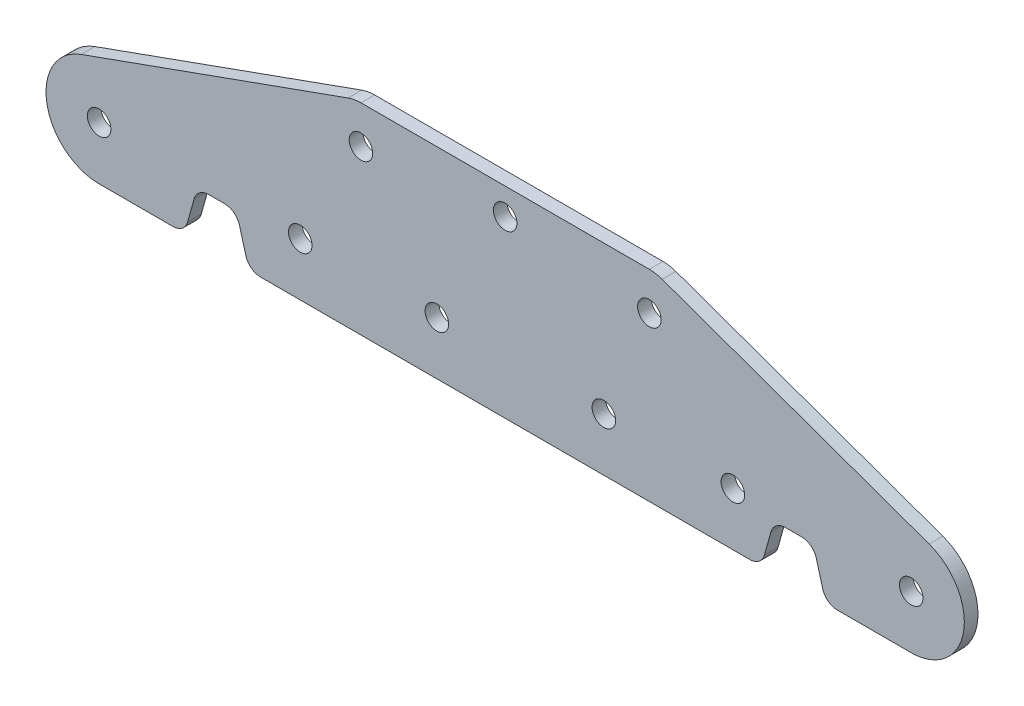
from build123d import *

# Parameters (mm, degrees)
SKETCH_1_R      = 1.55
EXTRUDE_1_DEPTH = 1.8
FILLET_1_R      = 2


with BuildPart() as part:
    # 草图1 → 凸台-拉伸1 (new body)
    with BuildSketch(Plane.XY):
        with BuildLine():
            Line((-19, 10.5), (19, 10.5))
            ThreePointArc((19, 10.5), (19.856766341, 10.426048258), (20.688188937, 10.206380575))
            Line((20.688188937, 10.206380575), (55.863464512, -2.411067196))
            ThreePointArc((55.863464512, -2.411067196), (60.396467561, -10.199472878), (53.5, -16))
            Line((53.5, -16), (42.25, -16))
            Line((42.25, -16), (40.57664504, -10))
            Line((40.57664504, -10), (35.42335496, -10))
            Line((35.42335496, -10), (33.75, -16))
            Line((33.75, -16), (-33.75, -16))
            Line((-33.75, -16), (-35.42335496, -10))
            Line((-35.42335496, -10), (-40.57664504, -10))
            Line((-40.57664504, -10), (-42.25, -16))
            Line((-42.25, -16), (-53.5, -16))
            ThreePointArc((-53.5, -16), (-60.396467561, -10.199472878), (-55.863464512, -2.411067196))
            Line((-55.863464512, -2.411067196), (-20.688188937, 10.206380575))
            ThreePointArc((-20.688188937, 10.206380575), (-19.856766341, 10.426048258), (-19, 10.5))
        make_face()
        with Locations((-27, -9)):
            Circle(SKETCH_1_R, mode=Mode.SUBTRACT)
        with Locations((-9, -9)):
            Circle(SKETCH_1_R, mode=Mode.SUBTRACT)
        with Locations((13, -9)):
            Circle(SKETCH_1_R, mode=Mode.SUBTRACT)
        with Locations((30, -9)):
            Circle(SKETCH_1_R, mode=Mode.SUBTRACT)
        with Locations((0, 7)):
            Circle(SKETCH_1_R, mode=Mode.SUBTRACT)
        with Locations((-53.5, -9)):
            Circle(SKETCH_1_R, mode=Mode.SUBTRACT)
        with Locations((53.5, -9)):
            Circle(SKETCH_1_R, mode=Mode.SUBTRACT)
        with Locations((-19, 5.5)):
            Circle(SKETCH_1_R, mode=Mode.SUBTRACT)
        with Locations((19, 5.5)):
            Circle(SKETCH_1_R, mode=Mode.SUBTRACT)
    extrude(amount=EXTRUDE_1_DEPTH)

    # 圆角1
    fillet_1_edges = [part.edges().sort_by_distance(p)[0] for p in [
        (42.25, -16, 0.9),
        (40.57664504, -10, 0.9),
        (35.42335496, -10, 0.9),
        (33.75, -16, 0.9),
        (-33.75, -16, 0.9),
        (-35.42335496, -10, 0.9),
        (-40.57664504, -10, 0.9),
        (-42.25, -16, 0.9),
    ]]
    fillet(fillet_1_edges, radius=FILLET_1_R)


solid = part.part
